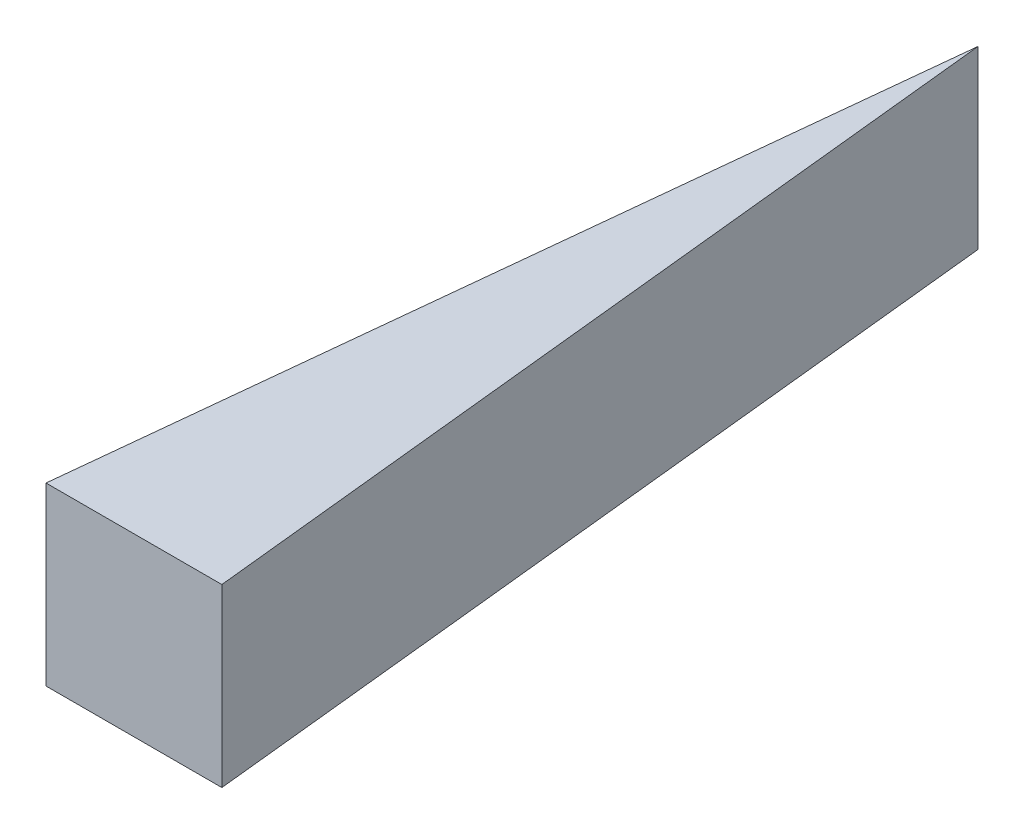
from build123d import *

# Parameters (mm, degrees)
BOSS_EXTRUDE1_DEPTH = 5


with BuildPart() as part:
    # Sketch1 → Boss-Extrude1 (new body)
    with BuildSketch(Plane(origin=(0, 0, 0), x_dir=(1, 0, 0), z_dir=(0, 1, 0))):
        Polygon((0, 24), (-2.5, 0), (2.5, 0), align=None)
    extrude(amount=BOSS_EXTRUDE1_DEPTH)


solid = part.part
